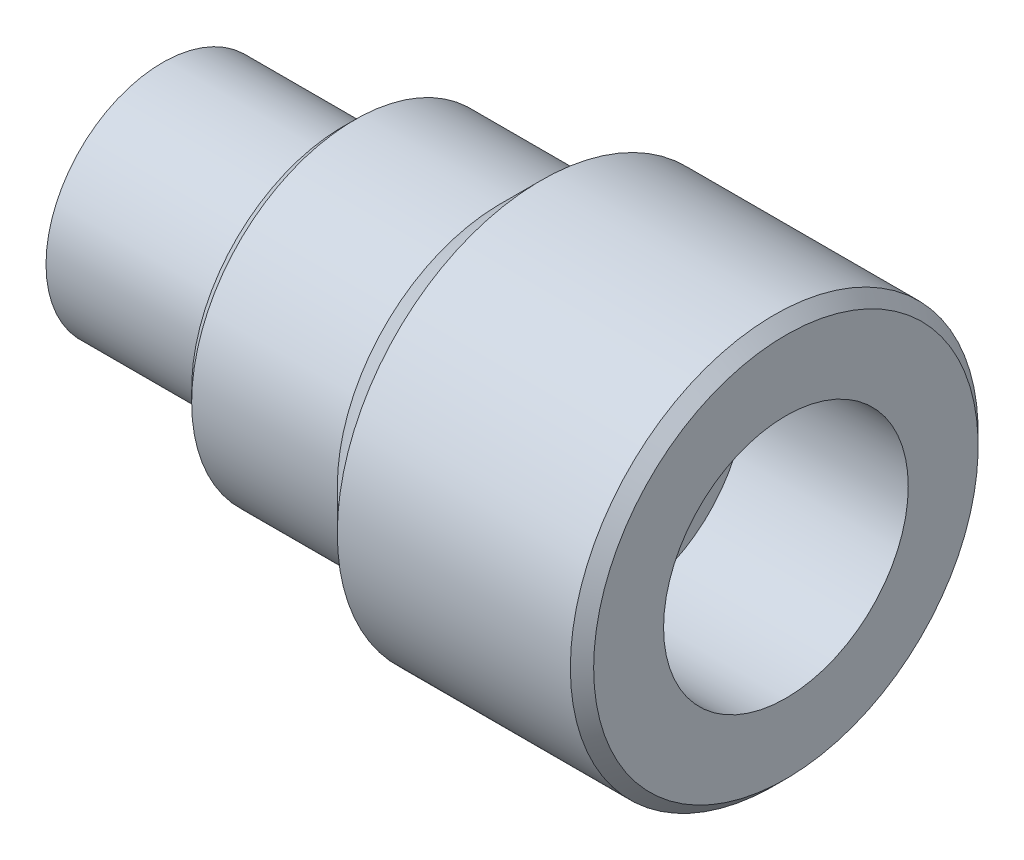
from build123d import *

# Parameters (mm, degrees)
CHAMFER1_SIZE       = 1
SKETCH2_R           = 10
SKETCH2_R_2         = 6
BOSS_EXTRUDE1_DEPTH = 30


with BuildPart() as part:
    # Sketch1 → Revolve1 (revolve)
    with BuildSketch(Plane.XY):
        Polygon((0, 10), (0, 14), (13.5, 14), (17, 17.5), (38, 17.5), (38, 10.5), (24, 10.5), (24, 6), (14.5, 6), (14.5, 10), align=None)
    revolve(axis=Axis((0, 0, 0), (1, 0, 0)))

    # Chamfer1
    chamfer1_edges = [part.edges().sort_by_distance(p)[0] for p in [
        (38, -17.5, 0),
        (0, -14, 0),
    ]]
    chamfer(chamfer1_edges, length=CHAMFER1_SIZE)


with BuildPart() as body_2:
    # Sketch2 → Boss-Extrude1 (new body)
    with BuildSketch(Plane.ZY.offset(-14.5)):
        Circle(SKETCH2_R)
        Circle(SKETCH2_R_2, mode=Mode.SUBTRACT)
    extrude(amount=BOSS_EXTRUDE1_DEPTH)


solid = Compound([part.part, body_2.part])
